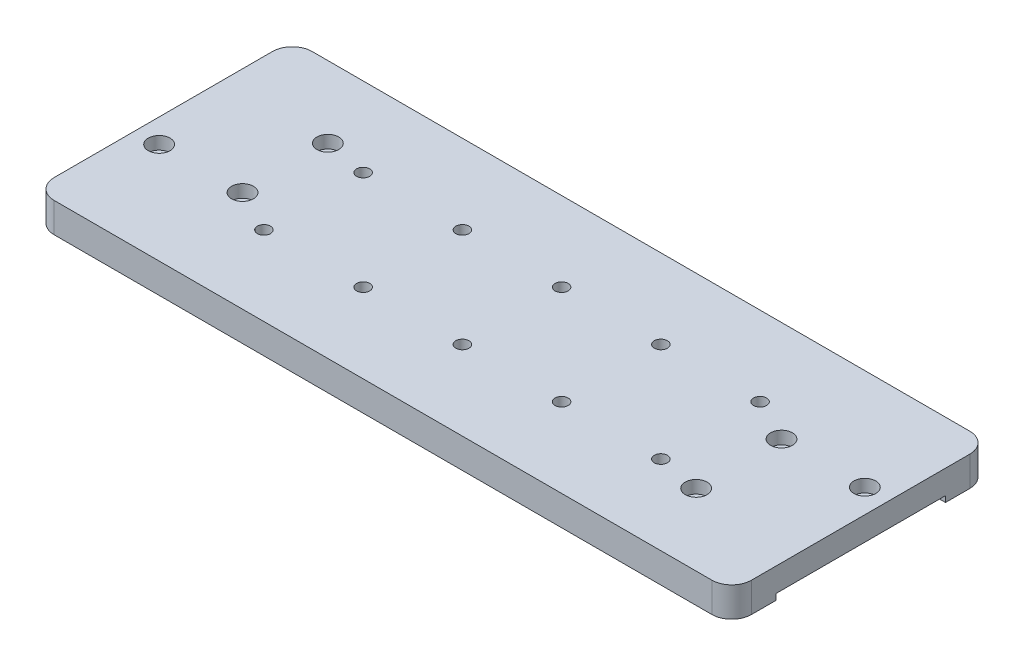
from build123d import *

# Parameters (mm, degrees)
ESTRUSIONE_ESTRUSIONE1_DEPTH                         = 15
TAGLIO_ESTRUSIONE1_DEPTH                             = 3
FORO_LAMATO_PER_VITE_M6_A_TESTA_CILINDRI_D           = 6.4
FORO_LAMATO_PER_VITE_M6_A_TESTA_CILINDRI_CBORE_D     = 11
FORO_LAMATO_PER_VITE_M6_A_TESTA_CILINDRI_CBORE_DEPTH = 6.4
RIPETIZIONECIRCOLARE1_COUNT                          = 2
FORO_PER_VITE_M6_1_D                                 = 6.6


with BuildPart() as part:
    # Schizzo1 → Estrusione-Estrusione1 (new body)
    with BuildSketch(Plane(origin=(0, -3, 0), x_dir=(1, 0, 0), z_dir=(0, 1, 0))):
        with BuildLine():
            Line((198.9, -65), (-132.5, -65))
            ThreePointArc((-132.5, -65), (-139.571067812, -62.071067812), (-142.5, -55))
            Line((-142.5, -55), (-142.5, 55))
            ThreePointArc((-142.5, 55), (-139.571067812, 62.071067812), (-132.5, 65))
            Line((-132.5, 65), (198.9, 65))
            ThreePointArc((198.9, 65), (205.971067812, 62.071067812), (208.9, 55))
            Line((208.9, 55), (208.9, -55))
            ThreePointArc((208.9, -55), (205.971067812, -62.071067812), (198.9, -65))
        make_face()
    extrude(amount=ESTRUSIONE_ESTRUSIONE1_DEPTH)

    # Schizzo2 → Taglio-Estrusione1 (cut)
    with BuildSketch(Plane(origin=(0, -3, 0), x_dir=(1, 0, 0), z_dir=(0, 1, 0))):
        with BuildLine():
            Line((149.372135955, 42.749691048), (208.9, 42.749691048))
            Line((208.9, 42.749691048), (208.9, -42.749691048))
            Line((208.9, -42.749691048), (149.372135955, -42.749691048))
            ThreePointArc((149.372135955, -42.749691048), (148.555639374, -42.92394919), (147.88142397, -43.416357715))
            ThreePointArc((147.88142397, -43.416357715), (142.071572875, -43.578118173), (142.233333333, -37.768267078))
            ThreePointArc((142.233333333, -37.768267078), (142.725741858, -37.094051674), (142.9, -36.277555093))
            Line((142.9, -36.277555093), (142.9, 36.277555093))
            ThreePointArc((142.9, 36.277555093), (142.725741858, 37.094051674), (142.233333333, 37.768267078))
            ThreePointArc((142.233333333, 37.768267078), (142.071572875, 43.578118173), (147.88142397, 43.416357715))
            ThreePointArc((147.88142397, 43.416357715), (148.555639374, 42.92394919), (149.372135955, 42.749691048))
        make_face()
    taglio_estrusione1 = extrude(amount=TAGLIO_ESTRUSIONE1_DEPTH, mode=Mode.SUBTRACT)

    # Foro lamato per Vite M6 a testa cilindri (through all)
    with Locations(Plane(origin=(0, 12, 0), x_dir=(1, 0, 0), z_dir=(0, 1, 0))):
        with Locations((154.9, -28.899213583), (154.9, 14.100786417), (196.9, 14.100786417)):
            foro_lamato_per_vite_m6_a_testa_cilindri = CounterBoreHole(FORO_LAMATO_PER_VITE_M6_A_TESTA_CILINDRI_D / 2, FORO_LAMATO_PER_VITE_M6_A_TESTA_CILINDRI_CBORE_D / 2, FORO_LAMATO_PER_VITE_M6_A_TESTA_CILINDRI_CBORE_DEPTH)

    # Specchia1: Taglio-Estrusione1 across plane
    add(taglio_estrusione1.mirror(Plane(origin=(33.2, 0, 0), x_dir=(0, 0, 1), z_dir=(1, 0, 0))), mode=Mode.SUBTRACT)

    # RipetizioneCircolare1: Foro lamato per Vite M6 a testa cilindri ×2 about axis
    ripetizionecircolare1_axis = Axis((33.2, 0, 0), (0, 1, 0))
    for i in range(1, RIPETIZIONECIRCOLARE1_COUNT):
        add(foro_lamato_per_vite_m6_a_testa_cilindri.rotate(ripetizionecircolare1_axis, i * 360 / RIPETIZIONECIRCOLARE1_COUNT), mode=Mode.SUBTRACT)

    # Foro per Vite M6-1 (through all)
    with Locations(Plane(origin=(0, -3, 0), x_dir=(-1, 0, 0), z_dir=(0, -1, 0))):
        with Locations((-133.2, 25), (66.8, -25), (66.8, 25), (-133.2, -25), (-33.2, -25), (-33.2, 25), (16.8, -25), (16.8, 25), (-83.2, 25), (-83.2, -25)):
            Hole(FORO_PER_VITE_M6_1_D / 2)


solid = part.part
